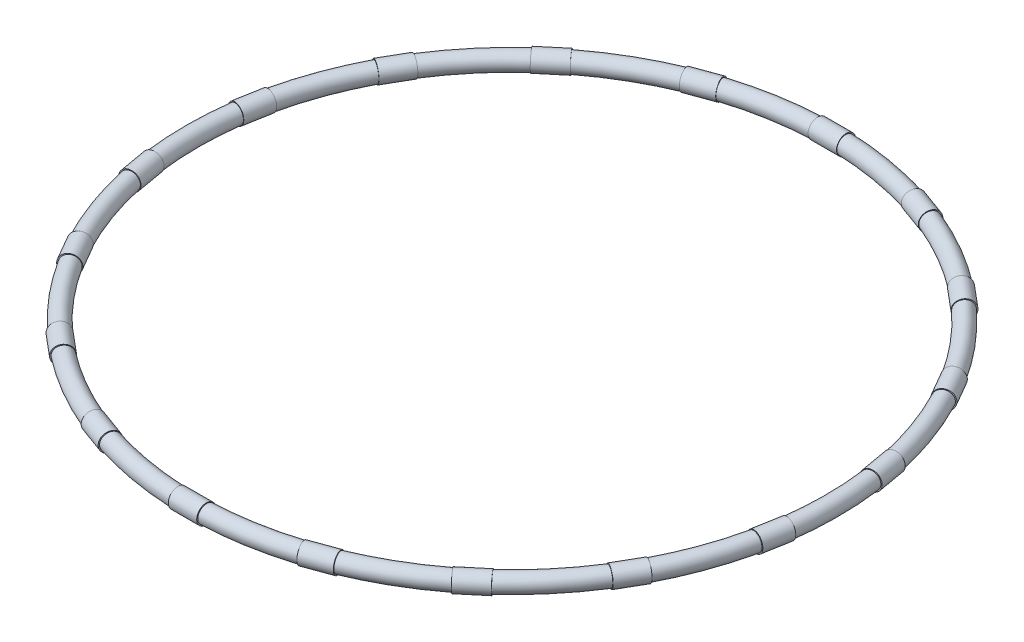
from build123d import *

# Parameters (mm, degrees)
ESBO_O1_R                = 0.62
ESBO_O6_R                = 0.675
RESSALTO_EXTRUS_O1_DEPTH = 2
PADR_OCIRCULAR1_COUNT    = 18


with BuildPart() as part:
    # Esboço1 → Revolução1 (revolve)
    with BuildSketch(Plane.XY):
        with Locations((22.5, 0)):
            Circle(ESBO_O1_R)
    revolve(axis=Axis((0, 0, 0), (0, 1, 0)))


with BuildPart() as body_2:
    # Esboço6 → Ressalto-extrusão1 (new body)
    with BuildSketch(Plane(origin=(1, 0, 0), x_dir=(0, 0, -1), z_dir=(1, 0, 0))):
        with Locations((22.5, 0)):
            Circle(ESBO_O6_R)
    ressalto_extrus_o1 = extrude(amount=-RESSALTO_EXTRUS_O1_DEPTH)


with BuildPart() as part_1:
    add(part.part)

    # PadrãoCircular1: Ressalto-extrusão1 ×18 about axis
    padr_ocircular1_axis = Axis((0, -0.715, 0), (0, 1, 0))
    for i in range(1, PADR_OCIRCULAR1_COUNT):
        add(ressalto_extrus_o1.rotate(padr_ocircular1_axis, i * 360 / PADR_OCIRCULAR1_COUNT))


solid = Compound([body_2.part, part_1.part])
